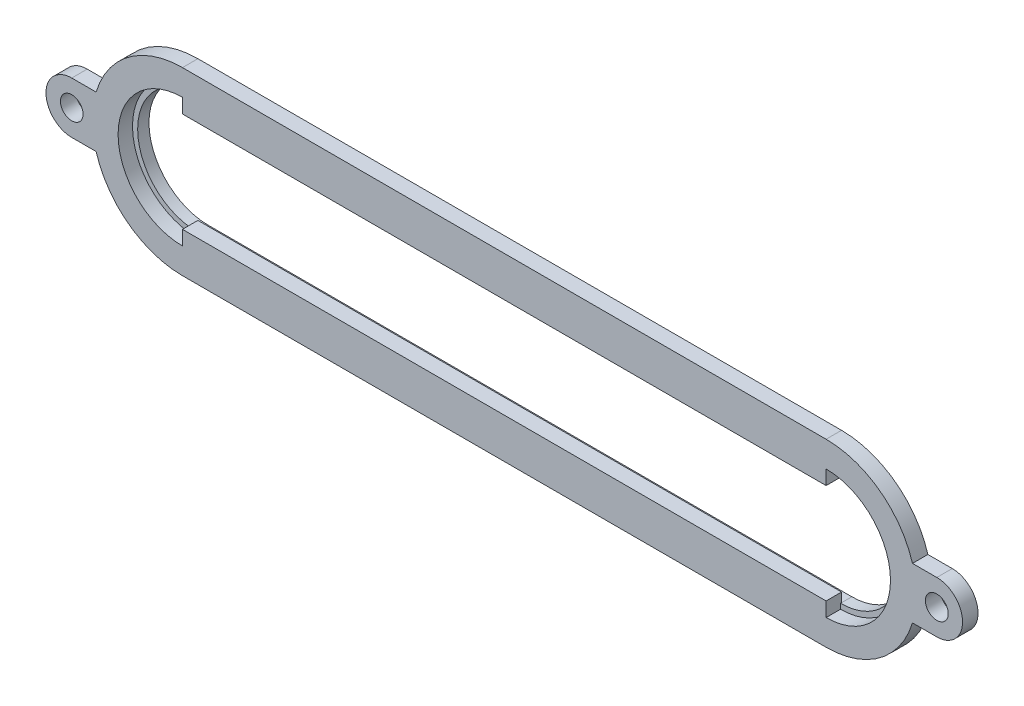
from build123d import *

# Parameters (mm, degrees)
BOSS_EXTRUDE5_DEPTH       = 3.81
SKETCH2_W                 = 158.75
SKETCH2_H                 = 1.27
BOSS_EXTRUDE14_DEPTH      = 2.54
BOSS_EXTRUDE14_DEPTH_BACK = 0.254
SKETCH3_R                 = 2.794
SKETCH3_R_2               = 2.820459539
BOSS_EXTRUDE15_DEPTH      = 3.81


with BuildPart() as part:
    # Sketch1 → Boss-Extrude5 (new body)
    with BuildSketch(Plane.XY):
        with BuildLine():
            Line((19.130596058, -22.225), (177.880596058, -22.225))
            ThreePointArc((177.880596058, -22.225), (200.105596058, 0), (177.880596058, 22.225))
            Line((177.880596058, 22.225), (19.130596058, 22.225))
            ThreePointArc((19.130596058, 22.225), (-3.094403942, 0), (19.130596058, -22.225))
        make_face()
        with BuildLine():
            Line((19.130596058, -12.319), (19.130596058, -15.875))
            ThreePointArc((19.130596058, -15.875), (3.255596058, 0), (19.130596058, 15.875))
            Line((19.130596058, 15.875), (19.130596058, 12.319))
            Line((19.130596058, 12.319), (177.880596058, 12.319))
            Line((177.880596058, 12.319), (177.880596058, 15.875))
            ThreePointArc((177.880596058, 15.875), (193.755596058, 0), (177.880596058, -15.875))
            Line((177.880596058, -15.875), (177.880596058, -12.319))
            Line((177.880596058, -12.319), (19.130596058, -12.319))
        make_face(mode=Mode.SUBTRACT)
    extrude(amount=BOSS_EXTRUDE5_DEPTH)

    # Sketch2 → Boss-Extrude14 (add, two sides)
    with BuildSketch(Plane(origin=(0, 0, 0), x_dir=(-1, 0, 0), z_dir=(0, 0, -1))) as boss_extrude14_sk:
        with BuildLine():
            ThreePointArc((-177.880596058, -14.605), (-192.485596058, 0), (-177.880596058, 14.605))
            Line((-177.880596058, 14.605), (-177.880596058, 15.875))
            ThreePointArc((-177.880596058, 15.875), (-193.755596058, 0), (-177.880596058, -15.875))
            Line((-177.880596058, -15.875), (-177.880596058, -14.605))
        make_face()
        Polygon((-177.880596058, 15.875), (-177.880596058, 14.605), (-19.130596058, 14.605), (-19.130596058, 14.665246221), (-19.130596058, 15.875), align=None)
        with Locations((-98.505596058, -15.24)):
            Rectangle(SKETCH2_W, SKETCH2_H)
        with BuildLine():
            Line((-19.130596058, 14.665246221), (-19.130596058, 14.605))
            ThreePointArc((-19.130596058, 14.605), (-4.525596058, 0), (-19.130596058, -14.605))
            Line((-19.130596058, -14.605), (-19.130596058, -15.875))
            ThreePointArc((-19.130596058, -15.875), (-3.255596058, 0), (-19.130596058, 15.875))
            Line((-19.130596058, 15.875), (-19.130596058, 14.665246221))
        make_face()
    extrude(amount=BOSS_EXTRUDE14_DEPTH)
    extrude(boss_extrude14_sk.sketch, amount=-BOSS_EXTRUDE14_DEPTH_BACK)

    # Sketch3 → Boss-Extrude15 (add)
    with BuildSketch(Plane.XY.offset(3.81)):
        with BuildLine():
            Line((-8.174403942, 6.35), (-2.167951427, 6.35))
            ThreePointArc((-2.167951427, 6.35), (-3.094403942, 0), (-2.167951427, -6.35))
            Line((-2.167951427, -6.35), (-8.174403942, -6.35))
            ThreePointArc((-8.174403942, -6.35), (-14.524403942, 0), (-8.174403942, 6.35))
        make_face()
        with Locations((-8.174403942, 0)):
            Circle(SKETCH3_R, mode=Mode.SUBTRACT)
        with BuildLine():
            Line((205.185596058, -6.35), (199.179143544, -6.35))
            ThreePointArc((199.179143544, -6.35), (200.105596058, 0), (199.179143544, 6.35))
            Line((199.179143544, 6.35), (205.185596058, 6.35))
            ThreePointArc((205.185596058, 6.35), (211.535596058, 0), (205.185596058, -6.35))
        make_face()
        with Locations((205.185596058, 0)):
            Circle(SKETCH3_R_2, mode=Mode.SUBTRACT)
    extrude(amount=-BOSS_EXTRUDE15_DEPTH)


solid = part.part
